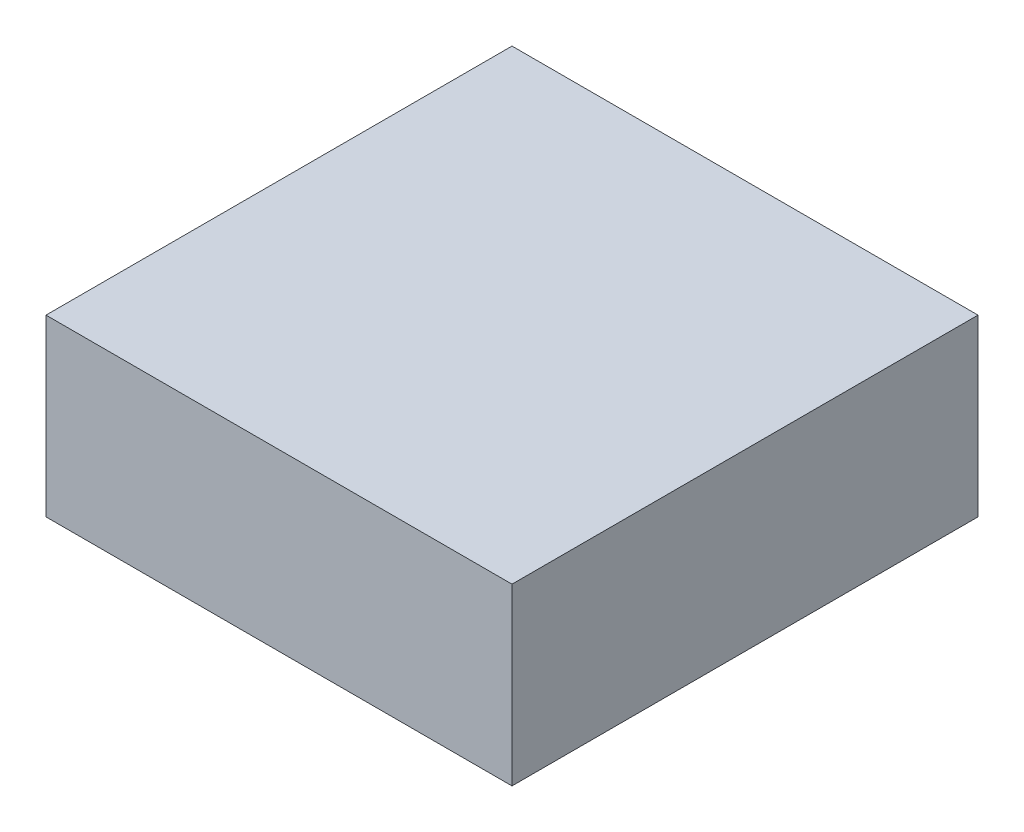
from build123d import *

# Parameters (mm, degrees)
SKETCH1_W           = 50.8
SKETCH1_H           = 50.8
BOSS_EXTRUDE1_DEPTH = 19.05


with BuildPart() as part:
    # Sketch1 → Boss-Extrude1 (new body)
    with BuildSketch(Plane(origin=(0, 0, 0), x_dir=(1, 0, 0), z_dir=(0, 1, 0))):
        with Locations((-25.4, 25.4)):
            Rectangle(SKETCH1_W, SKETCH1_H)
    extrude(amount=BOSS_EXTRUDE1_DEPTH)


solid = part.part
